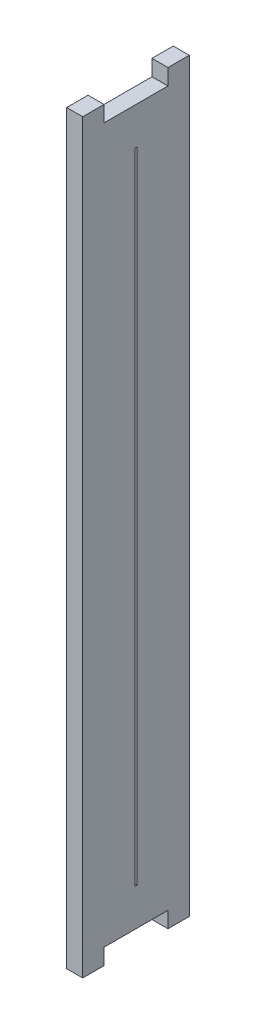
from build123d import *

# Parameters (mm, degrees)
SKETCH1_W           = 10
SKETCH1_H           = 70
BOSS_EXTRUDE1_DEPTH = 1.5
SKETCH3_W           = 0.2
SKETCH3_H           = 60
CUT_EXTRUDE2_DEPTH  = 10
SKETCH4_W           = 6
SKETCH4_H           = 1.5
CUT_EXTRUDE3_DEPTH  = 10


with BuildPart() as part:
    # Sketch1 → Boss-Extrude1 (new body)
    with BuildSketch(Plane(origin=(0, 0, 0), x_dir=(0, 0, -1), z_dir=(1, 0, 0))):
        with Locations((-5, 4.155844156)):
            Rectangle(SKETCH1_W, SKETCH1_H)
    extrude(amount=BOSS_EXTRUDE1_DEPTH)

    # Sketch3 → Cut-Extrude2 (cut)
    with BuildSketch(Plane(origin=(1.5, 0, 0), x_dir=(0, 0, -1), z_dir=(1, 0, 0))):
        with Locations((-5, 4.155844156)):
            Rectangle(SKETCH3_W, SKETCH3_H)
    extrude(amount=-CUT_EXTRUDE2_DEPTH, mode=Mode.SUBTRACT)

    # Sketch4 → Cut-Extrude3 (cut)
    with BuildSketch(Plane(origin=(1.5, 0, 0), x_dir=(0, 0, -1), z_dir=(1, 0, 0))):
        with Locations((-5, 38.405844156)):
            Rectangle(SKETCH4_W, SKETCH4_H)
        with Locations((-5, -30.094155844)):
            Rectangle(SKETCH4_W, SKETCH4_H)
    extrude(amount=-CUT_EXTRUDE3_DEPTH, mode=Mode.SUBTRACT)


solid = part.part
